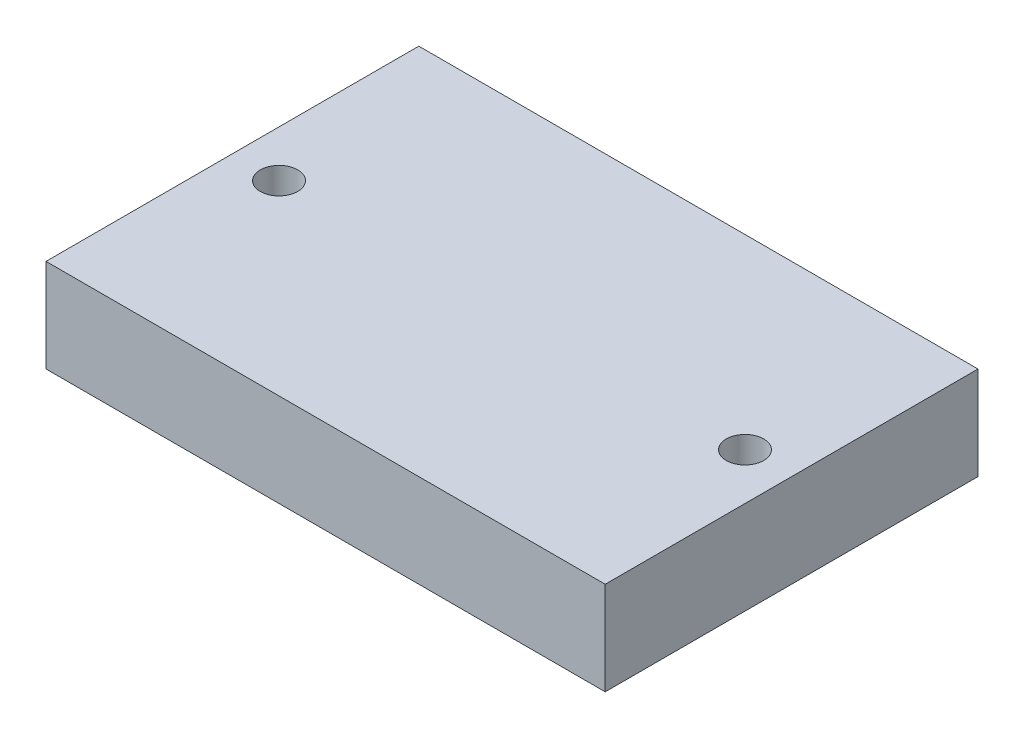
from build123d import *

# Parameters (mm, degrees)
SKETCH1_W               = 76.2
SKETCH1_H               = 50.8
BOSS_EXTRUDE1_DEPTH     = 12.7
F_1_4_20_TAPPED_HOLE1_D = 5.1054


with BuildPart() as part:
    # Sketch1 → Boss-Extrude1 (new body)
    with BuildSketch(Plane(origin=(0, 0, 0), x_dir=(1, 0, 0), z_dir=(0, 1, 0))):
        Rectangle(SKETCH1_W, SKETCH1_H)
    extrude(amount=BOSS_EXTRUDE1_DEPTH)

    # 1/4-20 Tapped Hole1 (through all)
    with Locations(Plane(origin=(0, 12.7, 0), x_dir=(1, 0, 0), z_dir=(0, 1, 0))):
        with Locations((-31.75, 0), (31.75, 0)):
            Hole(F_1_4_20_TAPPED_HOLE1_D / 2)


solid = part.part
